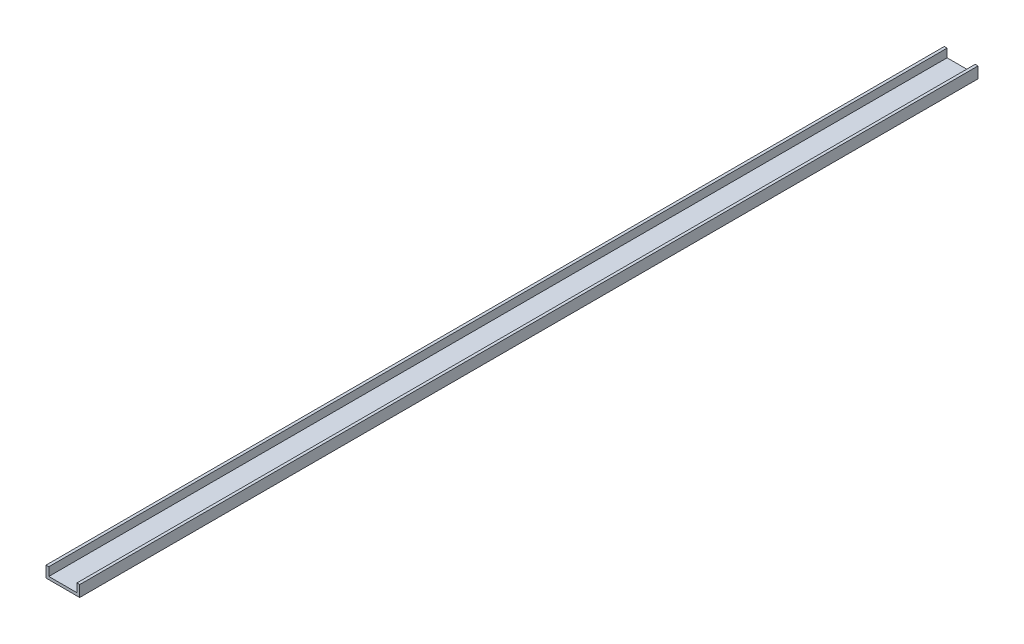
from build123d import *

# Parameters (mm, degrees)
EXTRUDE_F_DEPTH = 1016


with BuildPart() as part:
    # Sketch1 → Extrude f (new body)
    with BuildSketch(Plane.XY):
        Polygon((3.175, 3.175), (3.175, 12.7), (0, 12.7), (0, 0), (38.1, 0), (38.1, 12.7), (34.925, 12.7), (34.925, 3.175), align=None)
    extrude(amount=EXTRUDE_F_DEPTH)


solid = part.part
